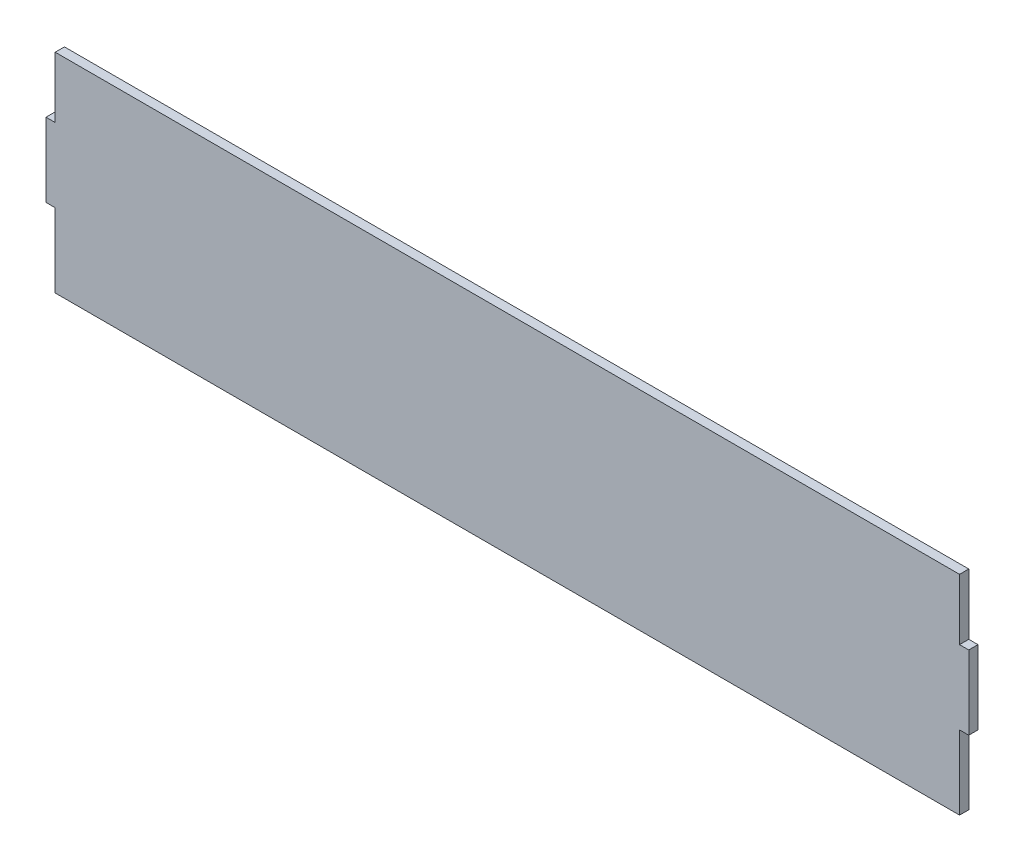
from build123d import *

# Parameters (mm, degrees)
BOSS_EXTRU_1_DEPTH = 5


with BuildPart() as part:
    # Esquisse1 → Boss.-Extru.1 (new body)
    with BuildSketch(Plane.XY):
        Polygon((500, 80), (495, 80), (495, 113), (5, 113), (5, 80), (0, 80), (0, 40), (5, 40), (5, 0), (495, 0), (495, 40), (500, 40), align=None)
    extrude(amount=BOSS_EXTRU_1_DEPTH)


solid = part.part
